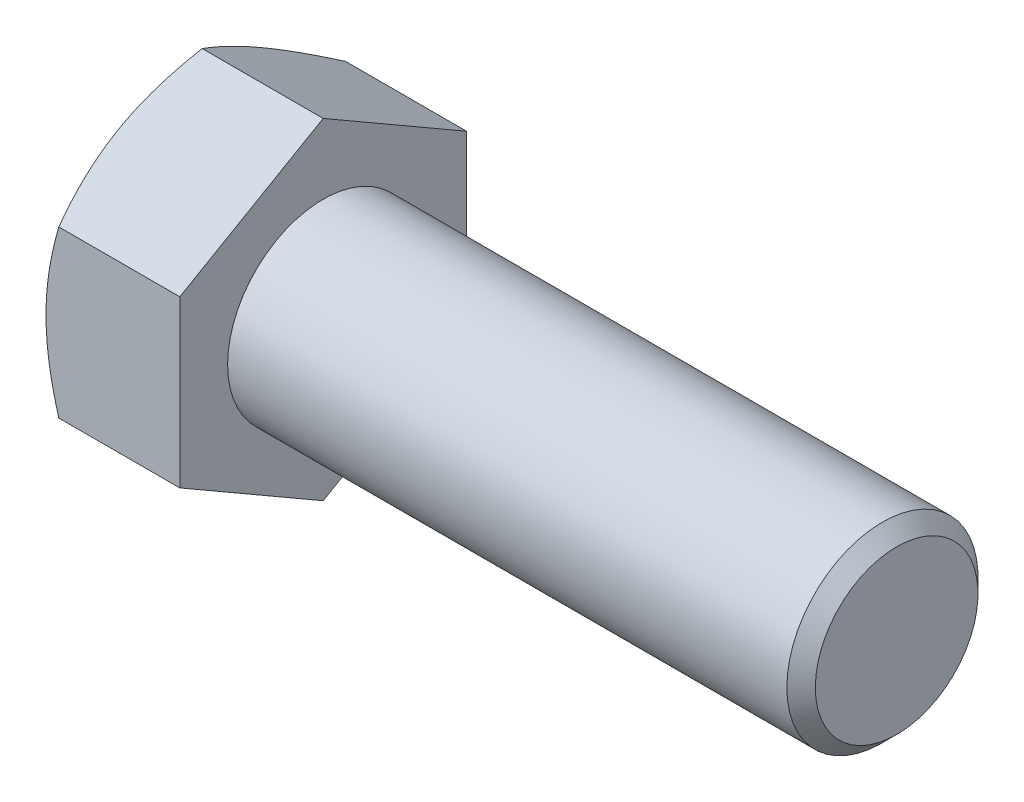
from build123d import *

# Parameters (mm, degrees)
BASEHEAD_DEPTH = 17.78


with BuildPart() as part:
    # Sketch1 → BaseHead (new body)
    with BuildSketch(Plane(origin=(0, 0, 0), x_dir=(0, 0, -1), z_dir=(1, 0, 0))):
        Polygon((19.05, 10.998522628), (19.05, -10.998522628), (0, -21.997045256), (-19.05, -10.998522628), (-19.05, 10.998522628), (0, 21.997045256), align=None)
    extrude(amount=BASEHEAD_DEPTH)

    # BodySke → BaseBody (revolve)
    with BuildSketch(Plane.XY):
        Polygon((0, 0), (93.98, 0), (93.98, 10.8077), (92.0877, 12.7), (0, 12.7), align=None)
    revolve(axis=Axis((0, 0, 0), (1, 0, 0)))

    # Sketch3 → HeadChamfer (revolve, cut)
    with BuildSketch(Plane.XY):
        Polygon((0, 19.05), (5.367651581, 28.347045256), (5.367651581, 34.697045256), (-12.7, 34.697045256), (-12.7, 19.05), align=None)
    revolve(axis=Axis((0, 0, 0), (1, 0, 0)), mode=Mode.SUBTRACT)


solid = part.part
